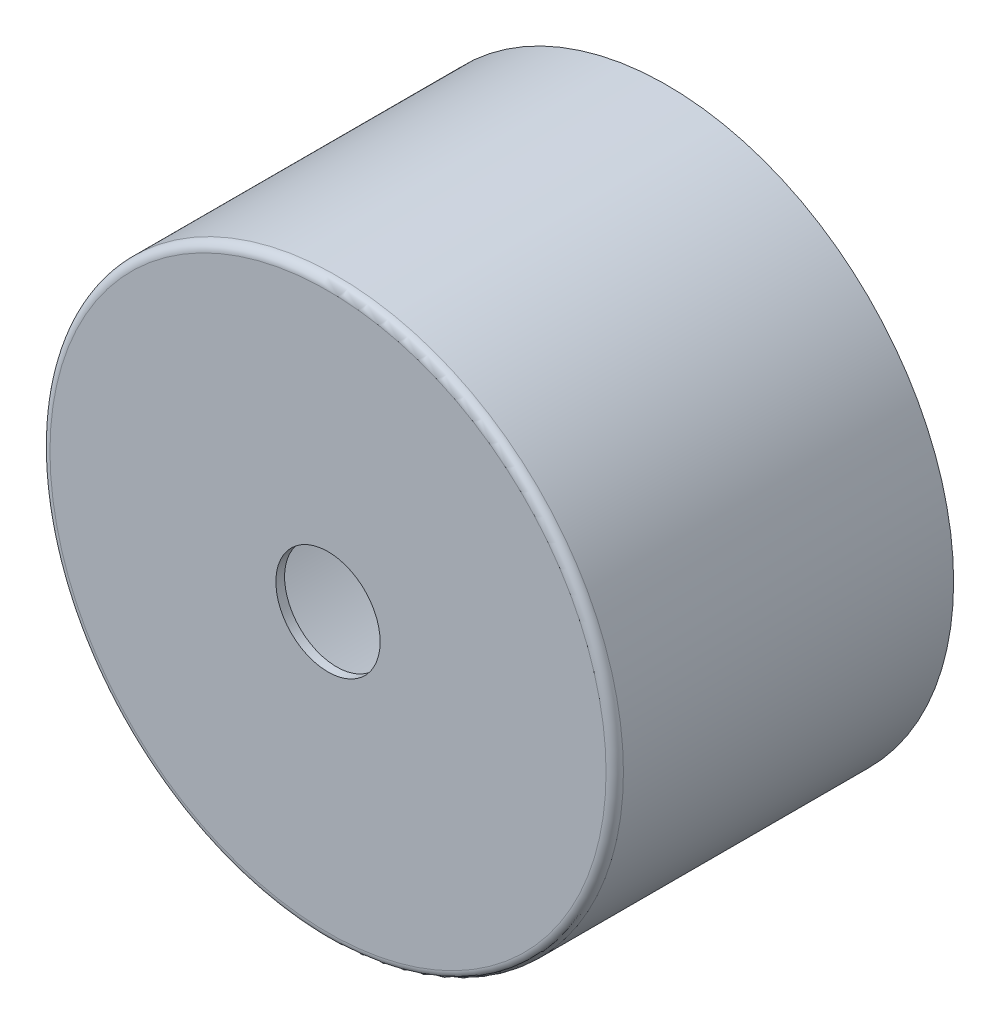
from build123d import *

# Parameters (mm, degrees)
SKETCH1_R           = 16.5
BOSS_EXTRUDE1_DEPTH = 19.5
SHELL1_T            = -0.5
SKETCH2_R           = 3
CUT_EXTRUDE1_DEPTH  = 31.409702399
FILLET1_R           = 0.5


with BuildPart() as part:
    # Sketch1 → Boss-Extrude1 (new body)
    with BuildSketch(Plane.XY):
        Circle(SKETCH1_R)
    extrude(amount=-BOSS_EXTRUDE1_DEPTH)

    # Shell1
    shell1_openings = [part.faces().sort_by_distance(p)[0] for p in [
        (0, 0, -19.5),
    ]]
    offset(amount=SHELL1_T, openings=shell1_openings, kind=Kind.INTERSECTION)

    # Sketch2 → Cut-Extrude1 (cut, through all)
    with BuildSketch(Plane.XY):
        Circle(SKETCH2_R)
    extrude(amount=-CUT_EXTRUDE1_DEPTH, mode=Mode.SUBTRACT)

    # Fillet1
    fillet1_edges = [part.edges().sort_by_distance(p)[0] for p in [
        (-16.5, 0, 0),
    ]]
    fillet(fillet1_edges, radius=FILLET1_R)


solid = part.part
